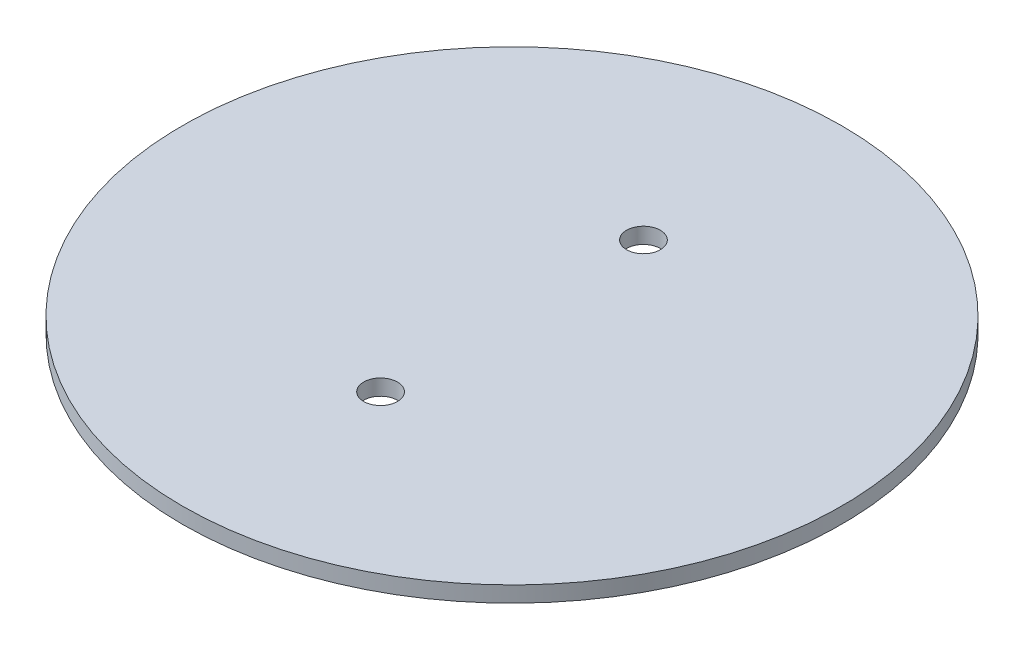
from build123d import *

# Parameters (mm, degrees)
SKETCH1_R           = 62.5
BOSS_EXTRUDE1_DEPTH = 3
SKETCH2_R           = 3.203476481
CUT_EXTRUDE1_DEPTH  = 4


with BuildPart() as part:
    # Sketch1 → Boss-Extrude1 (new body)
    with BuildSketch(Plane(origin=(0, 0, 0), x_dir=(1, 0, 0), z_dir=(0, 1, 0))):
        Circle(SKETCH1_R)
    extrude(amount=BOSS_EXTRUDE1_DEPTH)

    # Sketch2 → Cut-Extrude1 (cut, through all)
    with BuildSketch(Plane(origin=(0, 3, 0), x_dir=(1, 0, 0), z_dir=(0, 1, 0))):
        with Locations((0, 24.928251989)):
            Circle(SKETCH2_R)
        with Locations((0, -24.928251989)):
            Circle(SKETCH2_R)
    extrude(amount=-CUT_EXTRUDE1_DEPTH, mode=Mode.SUBTRACT)


solid = part.part
